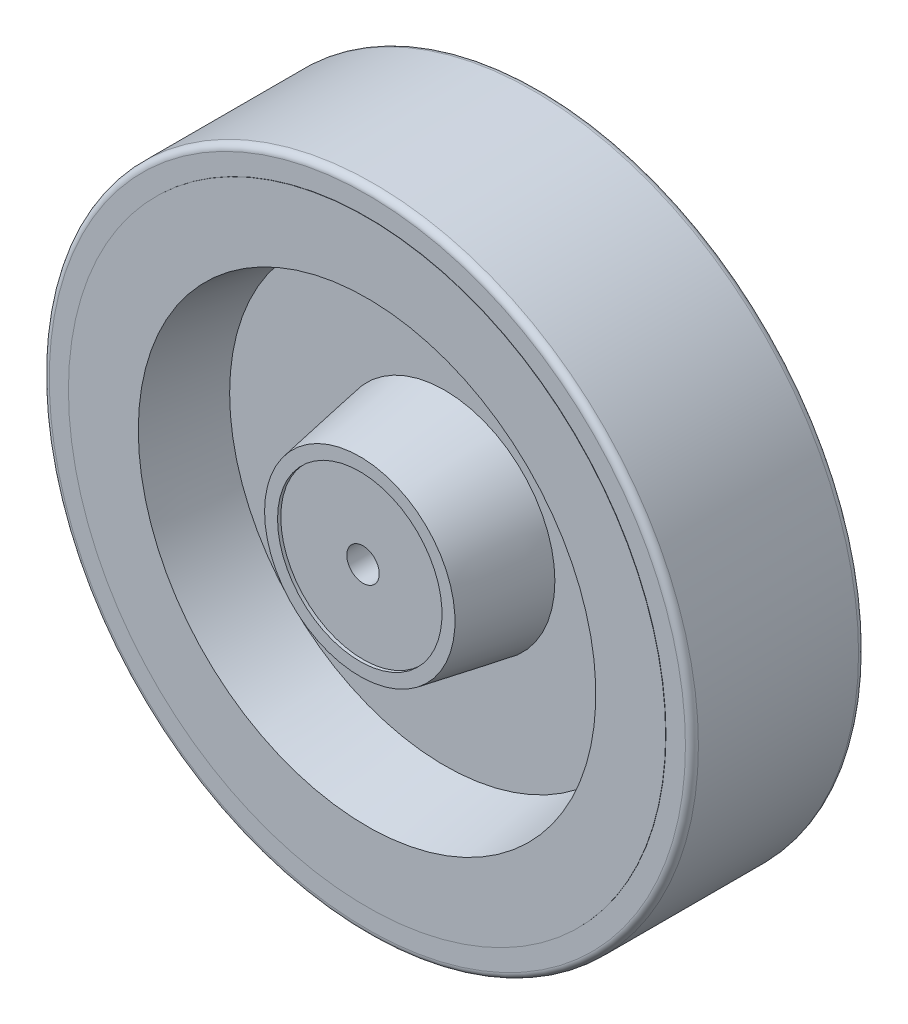
from build123d import *

# Parameters (mm, degrees)
SKETCH1_R           = 150
SKETCH1_R_2         = 138
BOSS_EXTRUDE1_DEPTH = 40
FILLET4_R           = 3
BOSS_EXTRUDE2_DEPTH = 12.5
BOSS_EXTRUDE3_DEPTH = 5.5
SKETCH6_R           = 8.061337792
BOSS_EXTRUDE4_DEPTH = 3
BOSS_EXTRUDE4_TAPER = 30
SKETCH8_R           = 7.5
CUT_EXTRUDE1_DEPTH  = 229.714341483


with BuildPart() as part:
    # Sketch1 → Boss-Extrude1 (new, symmetric)
    with BuildSketch(Plane.XY):
        Circle(SKETCH1_R)
        Circle(SKETCH1_R_2, mode=Mode.SUBTRACT)
    extrude(amount=BOSS_EXTRUDE1_DEPTH, both=True)

    # Fillet4
    fillet4_edges = [part.edges().sort_by_distance(p)[0] for p in [
        (-150, 0, -40),
        (-150, 0, 40),
    ]]
    fillet(fillet4_edges, radius=FILLET4_R)



with BuildPart() as body_2:
    # Sketch3 → Revolve6 (revolve)
    with BuildSketch(Plane(origin=(0, 0, 0), x_dir=(1, 0, 0), z_dir=(0, 1, 0))):
        Polygon((0, -42), (0, 42), (-38, 42), (-38, 43.5), (-44, 43.5), (-50.920833993, 4.25), (-99.390952242, 4.25), (-105.718469789, 40.135135225), (-138, 40.135135225), (-138, 0.135135225), (-138, 0), (-138, -0.135135225), (-138, -40.135135225), (-105.718469789, -40.135135225), (-99.390952242, -4.25), (-50.920833993, -4.25), (-44, -43.5), (-38, -43.5), (-38, -42), align=None)
    revolve(axis=Axis((0, 0, -71.241325943), (0, 0, 1)))


with BuildPart() as part_1:
    add(part.part)

    add(body_2.part)  # Boss-Extrude2 merges body 2
    # Sketch4 → Boss-Extrude2 (add, symmetric)
    with BuildSketch(Plane(origin=(0, 0, 0), x_dir=(1, 0, 0), z_dir=(0, 1, 0))):
        Polygon((-44.394294379, 24.25), (-44.394294379, 4.25), (-79.394294379, 4.25), (-79.394294379, 7.25), (-47.394294379, 24.25), align=None)
    extrude(amount=BOSS_EXTRUDE2_DEPTH, both=True)

    # Sketch5 → Boss-Extrude3 (add)
    with BuildSketch(Plane(origin=(-20.479018336, 0, -38.548740398), x_dir=(-0.8831157194574107, 0, 0.46915522596174897), z_dir=(-0.46915522596174897, 0, -0.8831157194574107))):
        Polygon((56.704671627, -4.570014345), (56.607735872, 4.737911997), (48.498367326, 9.307926342), (40.485934534, 4.570014345), (40.582870289, -4.737911997), (48.692238836, -9.307926342), align=None)
    extrude(amount=BOSS_EXTRUDE3_DEPTH)

    # Sketch6 → Boss-Extrude4 (add)
    with BuildSketch(Plane(origin=(-23.059372079, 0, -43.405876855), x_dir=(-0.8831157194574104, 0, 0.46915522596174986), z_dir=(-0.4691552259617498, 0, -0.8831157194574103))):
        with Locations((48.595303081, 0)):
            Circle(SKETCH6_R)
    extrude(amount=BOSS_EXTRUDE4_DEPTH, taper=BOSS_EXTRUDE4_TAPER)

    # Sketch7 → Revolve7 (revolve)
    with BuildSketch(Plane(origin=(0, 0, 0), x_dir=(1, 0, 0), z_dir=(0, 1, 0)), mode=Mode.PRIVATE) as revolve7_sk:
        with BuildLine():
            ThreePointArc((-74.132927223, 32.5476045), (-66.020984278, 33.177231974), (-61.79262097, 26.225901681))
            Line((-61.79262097, 26.225901681), (-67.382113799, 23.256483615))
            Line((-67.382113799, 23.256483615), (-74.132927223, 32.5476045))
        make_face()
    revolve(revolve7_sk.sketch.rotate(Axis((-67.382113799, 0, -23.256483615), (-0.5878091288499389, 0, -0.8089996465021947)), 180), axis=Axis((-67.382113799, 0, -23.256483615), (-0.5878091288499389, 0, -0.8089996465021947)))

    # Sketch8 → Cut-Extrude1 (cut, through all)
    with BuildSketch(Plane(origin=(0, 0, -42), x_dir=(-1, 0, 0), z_dir=(0, 0, -1))):
        Circle(SKETCH8_R)
    extrude(amount=-CUT_EXTRUDE1_DEPTH, mode=Mode.SUBTRACT)


solid = part_1.part
